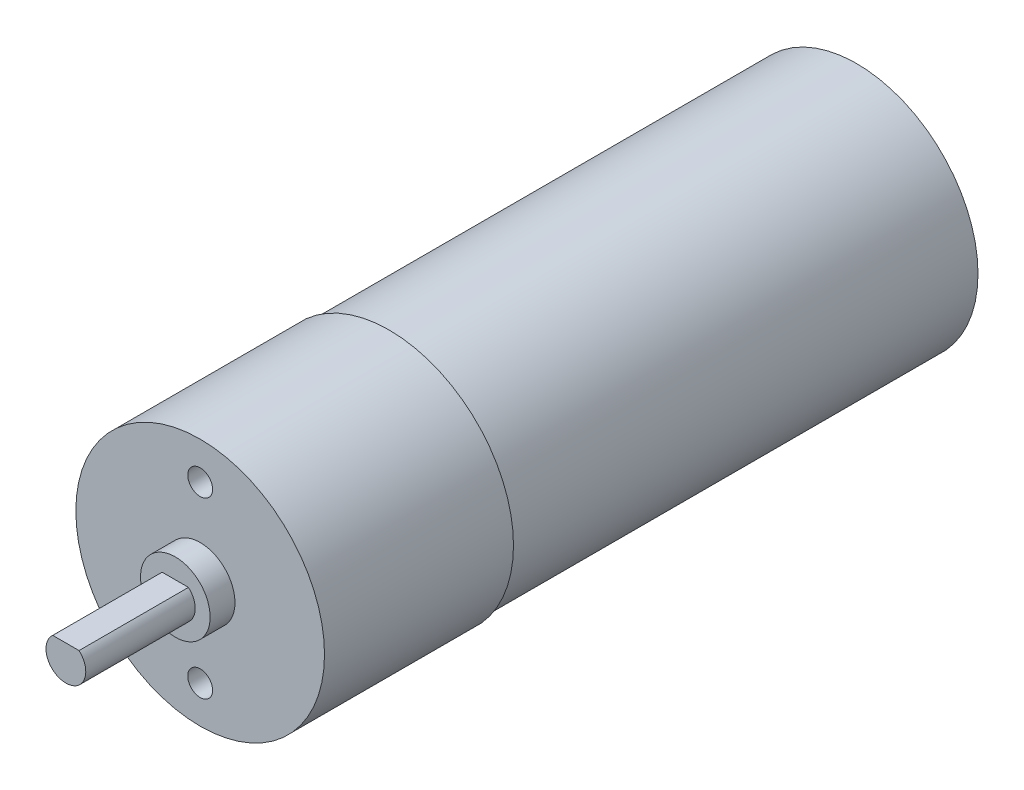
from build123d import *

# Parameters (mm, degrees)
SKETCH1_R                 = 12.2
BOSS_EXTRUDE1_DEPTH       = 47
BOSS_EXTRUDE2_START       = 47
SKETCH1_3_R               = 12.5
SKETCH1_3_R_2             = 12.2
BOSS_EXTRUDE2_DEPTH       = 19
SKETCH2_R                 = 3.5
SKETCH2_R_2               = 2
BOSS_EXTRUDE4_DEPTH       = 2.5
BOSS_EXTRUDE5_START       = 2.5
BOSS_EXTRUDE5_DEPTH       = 11
M3X0_5_TAPPED_HOLE1_D     = 2.5
M3X0_5_TAPPED_HOLE1_DEPTH = 20
M3X0_5_TAPPED_HOLE1_TIP   = 0.751075774


with BuildPart() as part:
    # Sketch1 → Boss-Extrude1 (new body)
    with BuildSketch(Plane.XY):
        Circle(SKETCH1_R)
    extrude(amount=BOSS_EXTRUDE1_DEPTH)

    # Sketch1_3 → Boss-Extrude2 (add)
    with BuildSketch(Plane.XY.offset(BOSS_EXTRUDE2_START)):
        Circle(SKETCH1_3_R)
        Circle(SKETCH1_3_R_2, mode=Mode.SUBTRACT)
        Circle(SKETCH1_3_R_2)
    extrude(amount=BOSS_EXTRUDE2_DEPTH)

    # Sketch2 → Boss-Extrude4 (add)
    with BuildSketch(Plane.XY.offset(66)):
        Circle(SKETCH2_R)
        Circle(SKETCH2_R_2, mode=Mode.SUBTRACT)
        with BuildLine():
            Line((1.322875656, 1.5), (-1.322875656, 1.5))
            ThreePointArc((-1.322875656, 1.5), (-0.822875656, -1.822875656), (2, 0))
            ThreePointArc((2, 0), (1.822875656, 0.822875656), (1.322875656, 1.5))
        make_face()
        with BuildLine():
            ThreePointArc((1.322875656, 1.5), (0, 2), (-1.322875656, 1.5))
            Line((-1.322875656, 1.5), (1.322875656, 1.5))
        make_face()
    extrude(amount=BOSS_EXTRUDE4_DEPTH)

    # Sketch2_4 → Boss-Extrude5 (add)
    with BuildSketch(Plane.XY.offset(66).offset(BOSS_EXTRUDE5_START)):
        with BuildLine():
            Line((1.322875656, 1.5), (-1.322875656, 1.5))
            ThreePointArc((-1.322875656, 1.5), (-0.822875656, -1.822875656), (2, 0))
            ThreePointArc((2, 0), (1.822875656, 0.822875656), (1.322875656, 1.5))
        make_face()
    extrude(amount=BOSS_EXTRUDE5_DEPTH)

    # M3x0.5 Tapped Hole1
    with Locations(Plane(origin=(0, 8.75, 66), x_dir=(1, 0, 0), z_dir=(0, 0, 1))):
        with Locations((0, 0), (0, -17.5)):
            Hole(M3X0_5_TAPPED_HOLE1_D / 2, depth=M3X0_5_TAPPED_HOLE1_DEPTH)
            with Locations((0, 0, -(M3X0_5_TAPPED_HOLE1_DEPTH + M3X0_5_TAPPED_HOLE1_TIP / 2))):  # 118° drill point
                Cone(0, M3X0_5_TAPPED_HOLE1_D / 2, M3X0_5_TAPPED_HOLE1_TIP, mode=Mode.SUBTRACT)


solid = part.part
